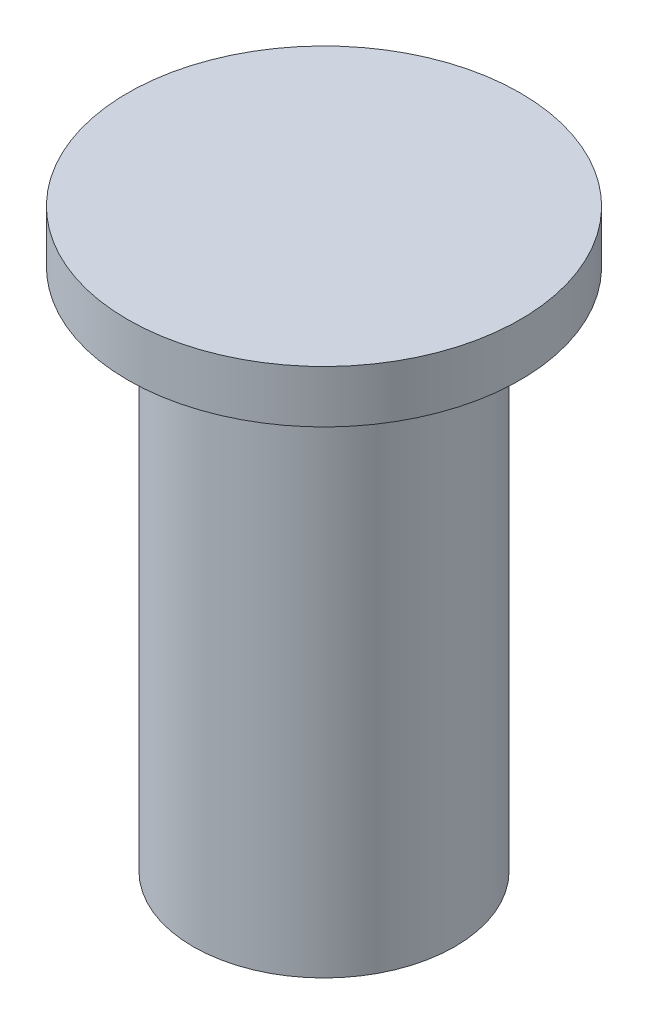
from build123d import *

# Parameters (mm, degrees)
SKETCH1_R           = 6.35
BOSS_EXTRUDE1_DEPTH = 25.4
SKETCH2_R           = 9.525
BOSS_EXTRUDE2_DEPTH = 2.54


with BuildPart() as part:
    # Sketch1 → Boss-Extrude1 (new body)
    with BuildSketch(Plane(origin=(0, 0, 0), x_dir=(1, 0, 0), z_dir=(0, 1, 0))):
        Circle(SKETCH1_R)
    extrude(amount=BOSS_EXTRUDE1_DEPTH)

    # Sketch2 → Boss-Extrude2 (add)
    with BuildSketch(Plane(origin=(0, 25.4, 0), x_dir=(1, 0, 0), z_dir=(0, 1, 0))):
        Circle(SKETCH2_R)
    extrude(amount=BOSS_EXTRUDE2_DEPTH)


solid = part.part
